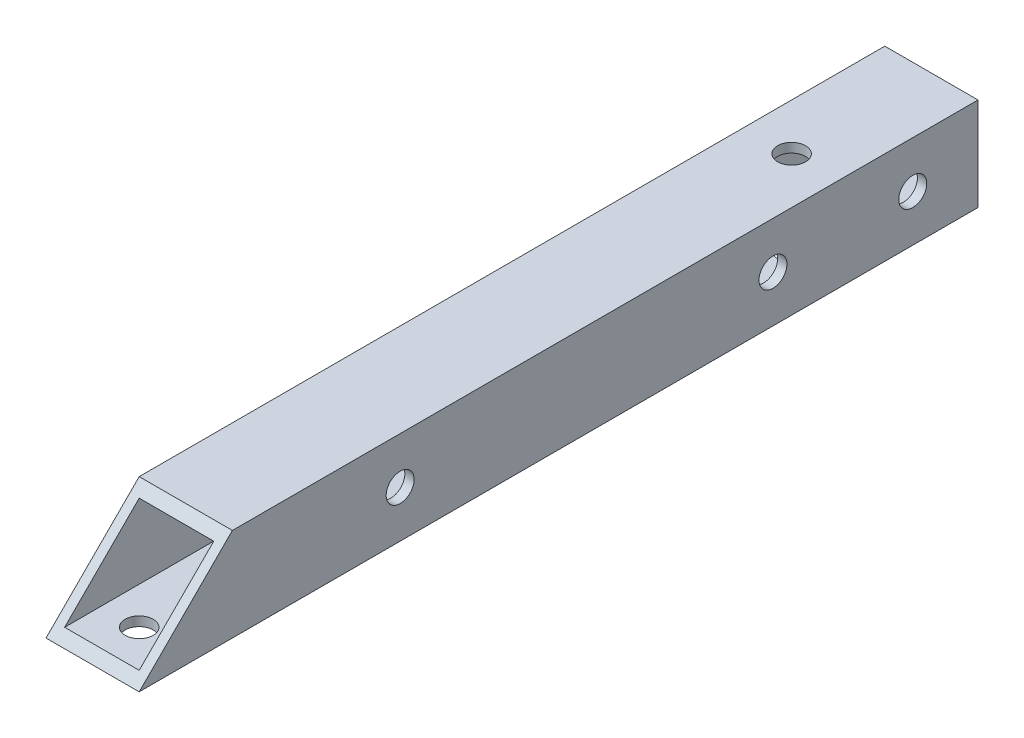
from build123d import *

# Parameters (mm, degrees)
SKETCH_1_W          = 10
SKETCH_1_H          = 10
SKETCH_1_W_2        = 8
SKETCH_1_H_2        = 8
EXTRUDE_1_DEPTH     = 90
SKETCH_2_R          = 1.5
CUT_EXTRUDE_1_DEPTH = 11
SKETCH_3_R          = 1.5
CUT_EXTRUDE_3_DEPTH = 11
CUT_EXTRUDE_4_DEPTH = 10


with BuildPart() as part:
    # 草图1 → 拉伸-薄壁1 (new body)
    with BuildSketch(Plane.XY):
        Rectangle(SKETCH_1_W, SKETCH_1_H)
        Rectangle(SKETCH_1_W_2, SKETCH_1_H_2, mode=Mode.SUBTRACT)
    extrude(amount=EXTRUDE_1_DEPTH)

    # 草图2 → 切除-拉伸1 (cut, through all)
    with BuildSketch(Plane(origin=(5, 0, 0), x_dir=(0, 0, -1), z_dir=(1, 0, 0))):
        with Locations((-62, 0)):
            Circle(SKETCH_2_R)
        with Locations((-7, 0)):
            Circle(SKETCH_2_R)
        with Locations((-22, 0)):
            Circle(SKETCH_2_R)
    extrude(amount=-CUT_EXTRUDE_1_DEPTH, mode=Mode.SUBTRACT)

    # 草图3 → 切除-拉伸3 (cut, through all)
    with BuildSketch(Plane(origin=(0, 5, 0), x_dir=(1, 0, 0), z_dir=(0, 1, 0))):
        with Locations((0, -15)):
            Circle(SKETCH_3_R)
        with Locations((0, -85)):
            Circle(SKETCH_3_R)
    extrude(amount=-CUT_EXTRUDE_3_DEPTH, mode=Mode.SUBTRACT)

    # 草图4 → 切除-拉伸4 (cut)
    with BuildSketch(Plane.ZY.offset(5)):
        Polygon((90, -5), (80, 5), (90, 5), align=None)
    extrude(amount=-CUT_EXTRUDE_4_DEPTH, mode=Mode.SUBTRACT)


solid = part.part
